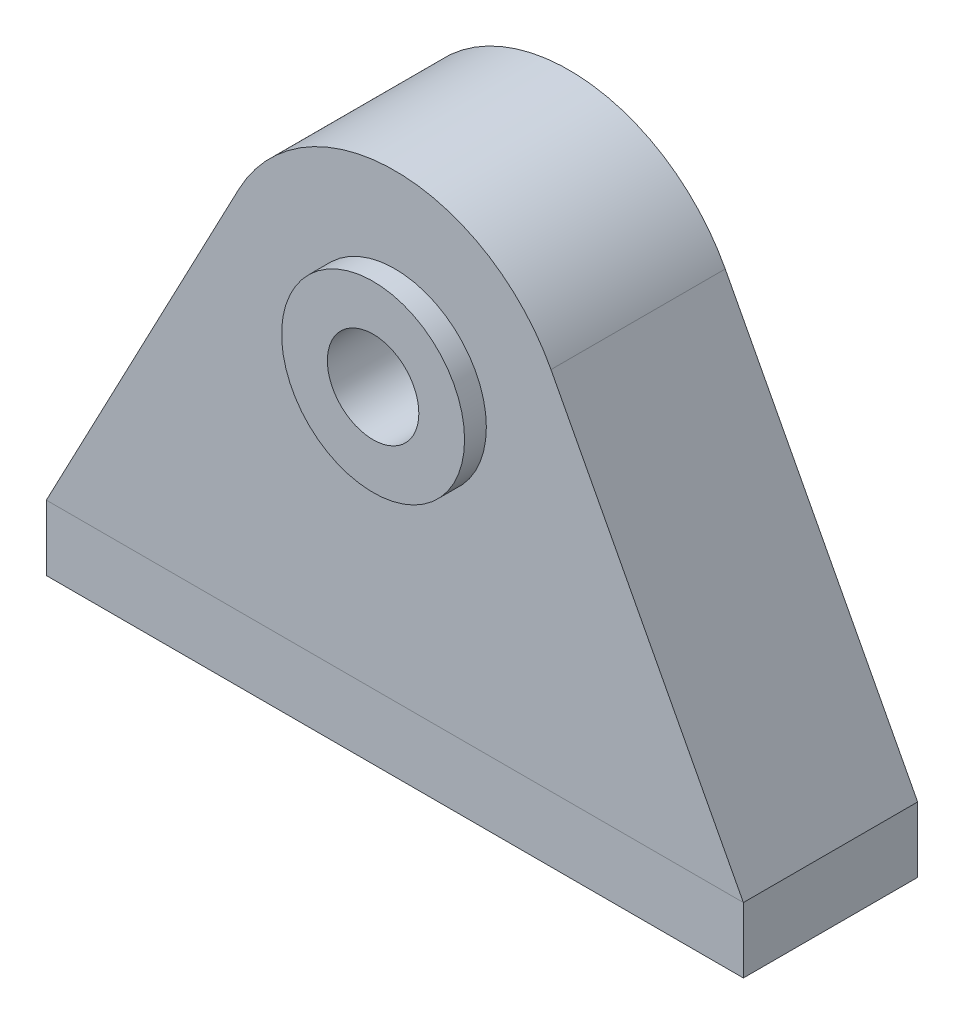
from build123d import *

# Parameters (mm, degrees)
SKETCH1_R               = 13.335
BOSS_EXTRUDE1_DEPTH     = 25.4
SKETCH7_R               = 26.67
BOSS_EXTRUDE3_DEPTH     = 31.75
CUT_EXTRUDE1_DEPTH      = 187.414413941
CUT_EXTRUDE1_DEPTH_BACK = 187.414413941
SKETCH10_R              = 13.335


with BuildPart() as part:
    # Sketch1 → Boss-Extrude1 (new, symmetric)
    with BuildSketch(Plane.XY):
        with BuildLine():
            Line((-101.6, 19.05), (-101.6, 0))
            Line((-101.6, 0), (101.6, 0))
            Line((101.6, 0), (101.6, 19.05))
            Line((101.6, 19.05), (45.510728203, 125.565242403))
            ThreePointArc((45.510728203, 125.565242403), (0, 153.035), (-45.510728203, 125.565242403))
            Line((-45.510728203, 125.565242403), (-101.6, 19.05))
        make_face()
        with Locations((0, 101.6)):
            Circle(SKETCH1_R, mode=Mode.SUBTRACT)
    extrude(amount=BOSS_EXTRUDE1_DEPTH, both=True)

    # Sketch7 → Boss-Extrude3 (add, symmetric)
    with BuildSketch(Plane.XY):
        with Locations((0, 101.6)):
            Circle(SKETCH7_R)
    extrude(amount=BOSS_EXTRUDE3_DEPTH, both=True)

    # Sketch10 → Cut-Extrude1 (cut, two sides: drawn at the far end of the back side and taken through both)
    with BuildSketch(Plane.XY.offset(-CUT_EXTRUDE1_DEPTH_BACK)):
        with Locations((0, 101.6)):
            Circle(SKETCH10_R)
    extrude(amount=CUT_EXTRUDE1_DEPTH + CUT_EXTRUDE1_DEPTH_BACK, mode=Mode.SUBTRACT)


solid = part.part
